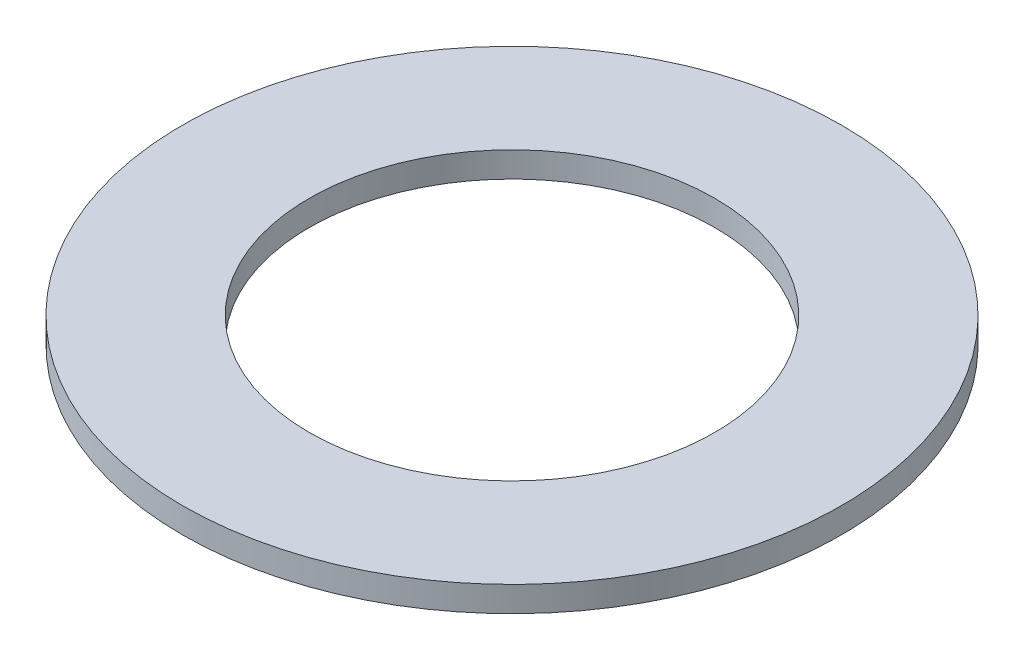
from build123d import *

# Parameters (mm, degrees)
SKETCH1_R           = 6.5
SKETCH1_R_2         = 4
BOSS_EXTRUDE1_DEPTH = 0.5


with BuildPart() as part:
    # Sketch1 → Boss-Extrude1 (new body)
    with BuildSketch(Plane(origin=(0, 0, 0), x_dir=(1, 0, 0), z_dir=(0, 1, 0))):
        Circle(SKETCH1_R)
        Circle(SKETCH1_R_2, mode=Mode.SUBTRACT)
    extrude(amount=BOSS_EXTRUDE1_DEPTH)


solid = part.part
